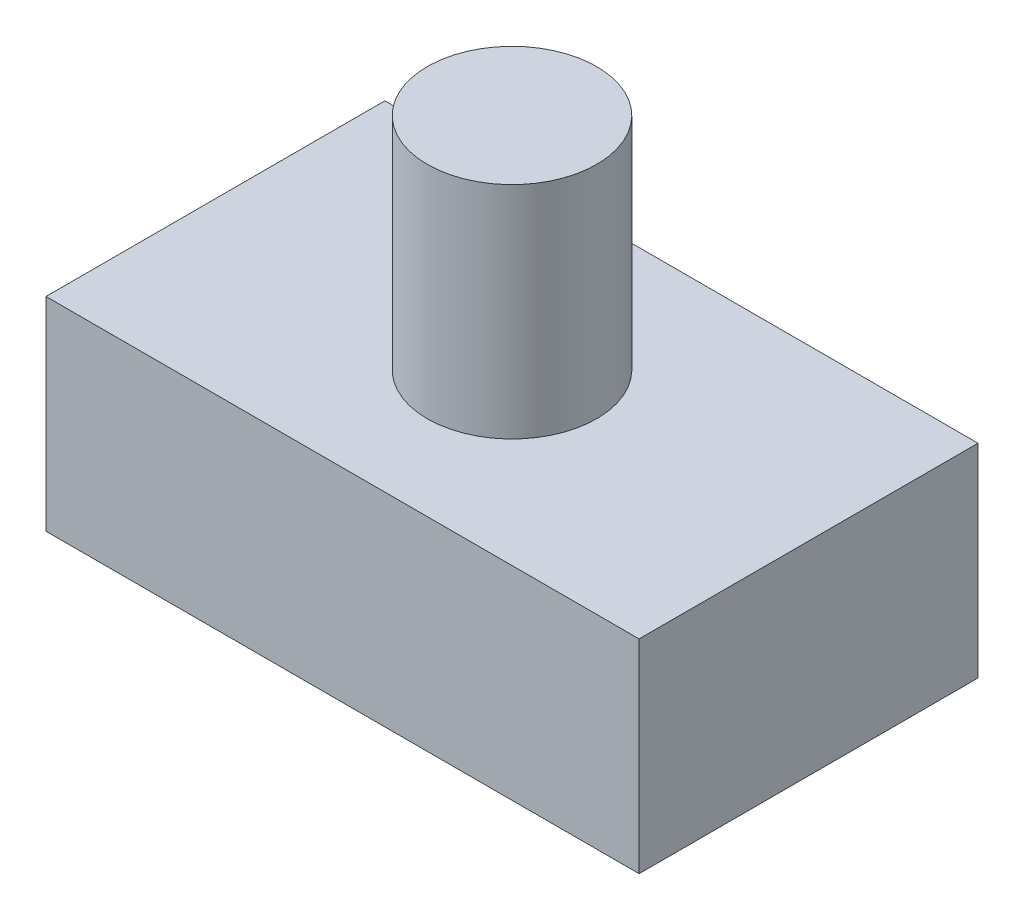
from build123d import *

# Parameters (mm, degrees)
SKETCH1_W           = 35
SKETCH1_H           = 20
BOSS_EXTRUDE1_DEPTH = 12
SKETCH1_3_R         = 5
BOSS_EXTRUDE2_DEPTH = 25


with BuildPart() as part:
    # Sketch1 → Boss-Extrude1 (new body)
    with BuildSketch(Plane(origin=(0, 0, 0), x_dir=(1, 0, 0), z_dir=(0, 1, 0))):
        Rectangle(SKETCH1_W, SKETCH1_H)
    extrude(amount=BOSS_EXTRUDE1_DEPTH)

    # Sketch1_3 → Boss-Extrude2 (add)
    with BuildSketch(Plane(origin=(0, 0, 0), x_dir=(1, 0, 0), z_dir=(0, 1, 0))):
        Circle(SKETCH1_3_R)
    extrude(amount=BOSS_EXTRUDE2_DEPTH)


solid = part.part
